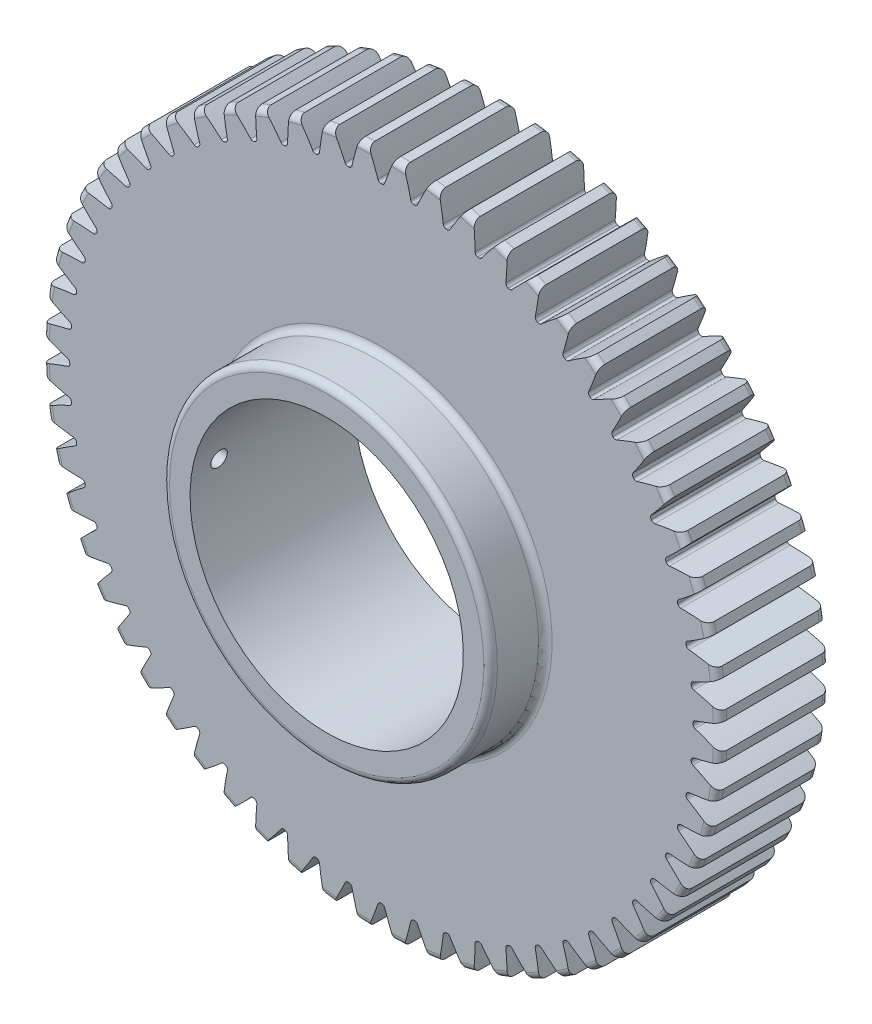
from build123d import *

# Parameters (mm, degrees)
FILLET2_R               = 1.24
CUT_EXTRUDE2_DEPTH      = 21
CIRPATTERN1_COUNT       = 60
SKETCH8_R               = 25
CUT_EXTRUDE3_DEPTH      = 1
CUT_EXTRUDE3_DEPTH_BACK = 31.0000001
SKETCH9_R               = 1.5
CUT_EXTRUDE4_DEPTH      = 2.54
CUT_EXTRUDE4_DEPTH_BACK = 37.953944057


with BuildPart() as part:
    # Sketch4 → Revolve1 (revolve)
    with BuildSketch(Plane(origin=(0, 0, 0), x_dir=(0, 0, -1), z_dir=(1, 0, 0))):
        Polygon((-30, 7.5), (-30, 30), (-20, 30), (-20, 62), (0, 62), (0, 7.5), align=None)
    revolve(axis=Axis((0, 0, 20), (0, 0, 1)))

    # Fillet2
    fillet2_edges = [part.edges().sort_by_distance(p)[0] for p in [
        (0, -62, 0),
        (0, -62, 20),
        (0, -30, 20),
        (0, -30, 30),
    ]]
    fillet(fillet2_edges, radius=FILLET2_R)

    # Sketch7 → Cut-Extrude2 (cut, through all)
    with BuildSketch(Plane.XY.offset(20)):
        with BuildLine():
            ThreePointArc((-0.055848304, 56.99997264), (0, 57), (0.055848304, 56.99997264))
            ThreePointArc((0.055848304, 56.99997264), (0.405150221, 57.111701617), (0.624192341, 57.405837203))
            ThreePointArc((0.624192341, 57.405837203), (1.460508753, 59.697838343), (2.389315421, 61.953943957))
            ThreePointArc((2.389315421, 61.953943957), (0, 62), (-2.389315421, 61.953943957))
            ThreePointArc((-2.389315421, 61.953943957), (-1.460508753, 59.697838343), (-0.624192341, 57.405837203))
            ThreePointArc((-0.624192341, 57.405837203), (-0.405150221, 57.111701617), (-0.055848304, 56.99997264))
        make_face()
    cut_extrude2 = extrude(amount=-CUT_EXTRUDE2_DEPTH, mode=Mode.SUBTRACT)

    # CirPattern1: Cut-Extrude2 ×60 about axis
    cirpattern1_axis = Axis((0, 0, 0), (0, 0, 1))
    for i in range(1, CIRPATTERN1_COUNT):
        add(cut_extrude2.rotate(cirpattern1_axis, i * 360 / CIRPATTERN1_COUNT), mode=Mode.SUBTRACT)

    # Sketch8 → Cut-Extrude3 (cut, two sides)
    with BuildSketch(Plane.XY.offset(30)) as cut_extrude3_sk:
        Circle(SKETCH8_R)
    extrude(amount=CUT_EXTRUDE3_DEPTH, mode=Mode.SUBTRACT)
    extrude(cut_extrude3_sk.sketch, amount=-CUT_EXTRUDE3_DEPTH_BACK, mode=Mode.SUBTRACT)

    # Sketch9 → Cut-Extrude4 (cut, two sides)
    with BuildSketch(Plane(origin=(-25, 0, 0), x_dir=(0, 0, -1), z_dir=(1, 0, 0))) as cut_extrude4_sk:
        with Locations((-24.95, 3.570652979)):
            Circle(SKETCH9_R)
    extrude(amount=CUT_EXTRUDE4_DEPTH, mode=Mode.SUBTRACT)
    extrude(cut_extrude4_sk.sketch, amount=-CUT_EXTRUDE4_DEPTH_BACK, mode=Mode.SUBTRACT)


solid = part.part
